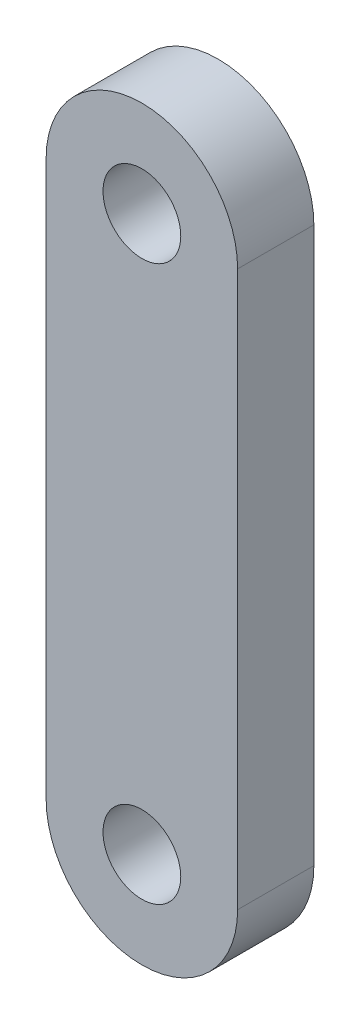
from build123d import *

# Parameters (mm, degrees)
SKETCH1_R           = 3.2385
BOSS_EXTRUDE1_DEPTH = 6.35


with BuildPart() as part:
    # Sketch1 → Boss-Extrude1 (new body)
    with BuildSketch(Plane.XY):
        with BuildLine():
            Line((7.9756, 23.114), (7.9756, -23.114))
            ThreePointArc((7.9756, -23.114), (0, -31.0896), (-7.9756, -23.114))
            Line((-7.9756, -23.114), (-7.9756, 23.114))
            ThreePointArc((-7.9756, 23.114), (0, 31.0896), (7.9756, 23.114))
        make_face()
        with Locations((0, 23.114)):
            Circle(SKETCH1_R, mode=Mode.SUBTRACT)
        with Locations((0, -23.114)):
            Circle(SKETCH1_R, mode=Mode.SUBTRACT)
    extrude(amount=BOSS_EXTRUDE1_DEPTH)


solid = part.part
